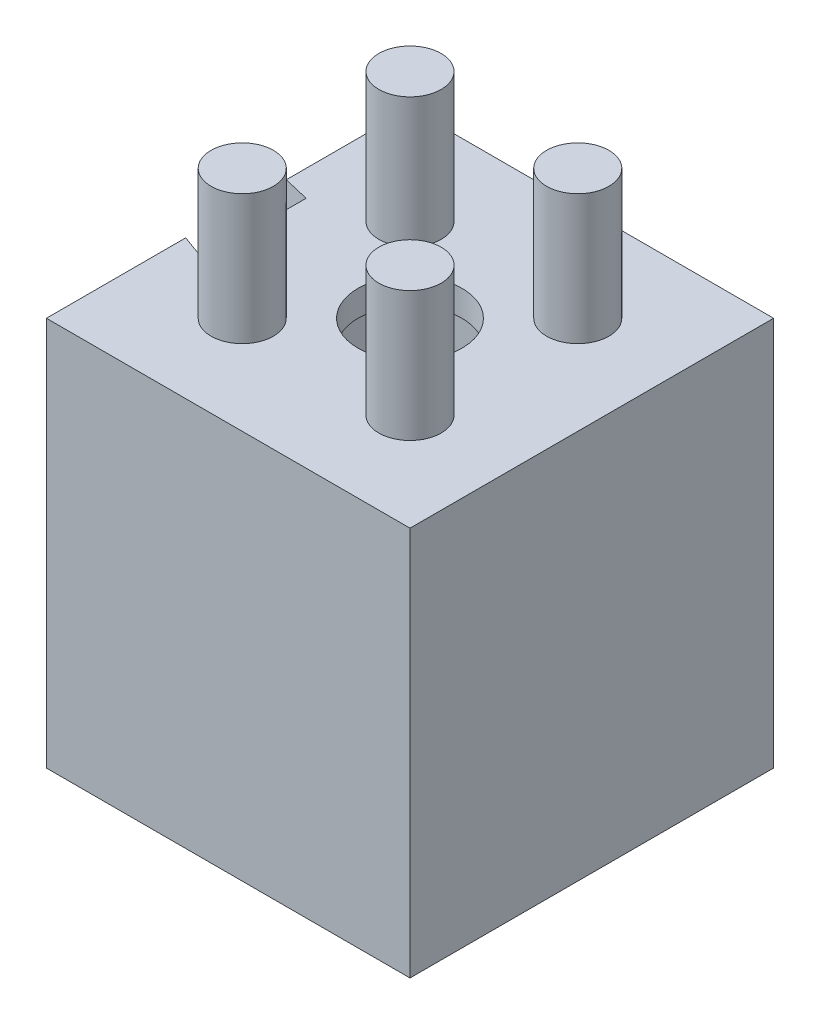
from build123d import *

# Parameters (mm, degrees)
SKETCH1_W           = 12
SKETCH1_H           = 12
SKETCH1_R           = 2
BOSS_EXTRUDE2_DEPTH = 1
BOSS_EXTRUDE5_DEPTH = 15
SKETCH4_R           = 1.2
BOSS_EXTRUDE6_DEPTH = 5


with BuildPart() as part:
    # Sketch1 → Boss-Extrude2 (new body)
    with BuildSketch(Plane(origin=(0, 0, 0), x_dir=(1, 0, 0), z_dir=(0, 1, 0))):
        with Locations((-5.898996881, 2.563822752)):
            Rectangle(SKETCH1_W, SKETCH1_H)
        with Locations((-5.898996881, 2.563822752)):
            Circle(SKETCH1_R, mode=Mode.SUBTRACT)
    extrude(amount=BOSS_EXTRUDE2_DEPTH)

    # Sketch3 → Boss-Extrude5 (add)
    with BuildSketch(Plane(origin=(0, 1, 0), x_dir=(1, 0, 0), z_dir=(0, 1, 0))):
        Polygon((-12.898996881, -4.436177248), (-12.898996881, 0.92811169), (-11.898996881, 0.563822752), (-11.898996881, -3.436177248), (0.101003119, -3.436177248), (0.101003119, 8.563822752), (-11.898996881, 8.563822752), (-11.898996881, 4.563822752), (-12.898996881, 4.800920569), (-12.898996881, 9.563822752), (1.101003119, 9.563822752), (1.101003119, -4.436177248), align=None)
    extrude(amount=-BOSS_EXTRUDE5_DEPTH)

    # Sketch4 → Boss-Extrude6 (add)
    with BuildSketch(Plane(origin=(0, 1, 0), x_dir=(1, 0, 0), z_dir=(0, 1, 0))):
        with Locations((-9.128696242, 5.793522112)):
            Circle(SKETCH4_R)
        with Locations((-2.66929752, 5.793522112)):
            Circle(SKETCH4_R)
        with Locations((-2.66929752, -0.665876609)):
            Circle(SKETCH4_R)
        with Locations((-9.128696242, -0.665876609)):
            Circle(SKETCH4_R)
    extrude(amount=BOSS_EXTRUDE6_DEPTH)


solid = part.part
